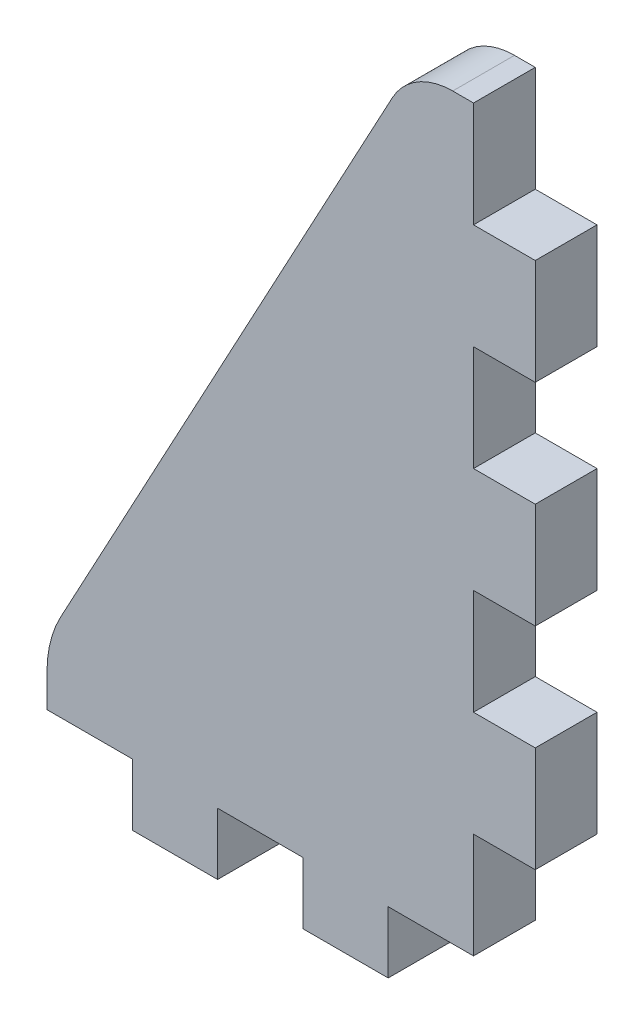
from build123d import *

# Parameters (mm, degrees)
BOSS_EXTRUDE1_DEPTH = 2.7


with BuildPart() as part:
    # Sketch1 → Boss-Extrude1 (new body)
    with BuildSketch(Plane.XY):
        with BuildLine():
            Line((7.975, 17.5), (7.066267392, 17.5))
            ThreePointArc((7.066267392, 17.5), (5.52829673, 17.075780705), (4.425283954, 15.923097495))
            Line((4.425283954, 15.923097495), (-10.076639064, -10.98956215))
            ThreePointArc((-10.076639064, -10.98956215), (-10.52310248, -12.138320442), (-10.675, -13.361391307))
            Line((-10.675, -13.361391307), (-10.675, -14.8))
            Line((-10.675, -14.8), (-6.945, -14.8))
            Line((-6.945, -14.8), (-6.945, -17.5))
            Line((-6.945, -17.5), (-3.215, -17.5))
            Line((-3.215, -17.5), (-3.215, -14.8))
            Line((-3.215, -14.8), (0.515, -14.8))
            Line((0.515, -14.8), (0.515, -17.5))
            Line((0.515, -17.5), (4.245, -17.5))
            Line((4.245, -17.5), (4.245, -14.8))
            Line((4.245, -14.8), (7.975, -14.8))
            Line((7.975, -14.8), (7.975, -10.185714286))
            Line((7.975, -10.185714286), (10.675, -10.185714286))
            Line((10.675, -10.185714286), (10.675, -5.571428571))
            Line((10.675, -5.571428571), (7.975, -5.571428571))
            Line((7.975, -5.571428571), (7.975, -0.957142857))
            Line((7.975, -0.957142857), (10.675, -0.957142857))
            Line((10.675, -0.957142857), (10.675, 3.657142857))
            Line((10.675, 3.657142857), (7.975, 3.657142857))
            Line((7.975, 3.657142857), (7.975, 8.271428571))
            Line((7.975, 8.271428571), (10.675, 8.271428571))
            Line((10.675, 8.271428571), (10.675, 12.885714286))
            Line((10.675, 12.885714286), (7.975, 12.885714286))
            Line((7.975, 12.885714286), (7.975, 17.5))
        make_face()
    extrude(amount=-BOSS_EXTRUDE1_DEPTH)


solid = part.part
